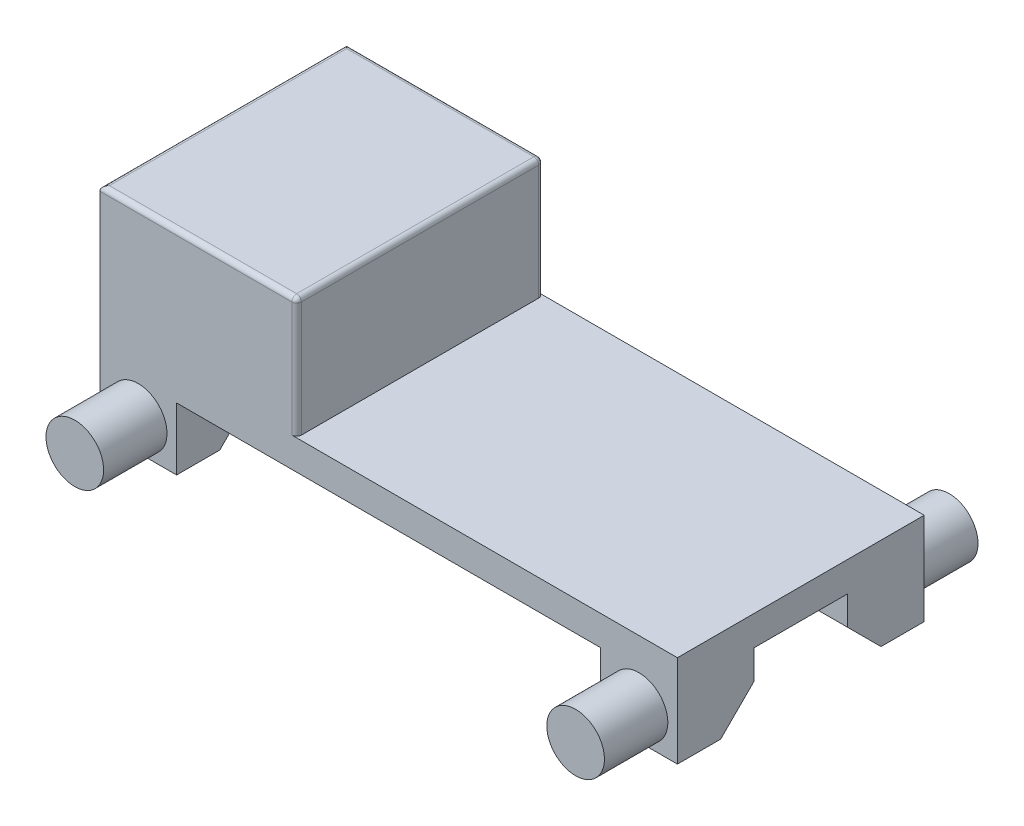
from build123d import *

# Parameters (mm, degrees)
SKETCH_1_W      = 1203
SKETCH_1_H      = 514
EXTRUDE_1_DEPTH = 62
SKETCH_2_W      = 410
SKETCH_2_H      = 514
EXTRUDE_2_DEPTH = 250
FILLET_1_R      = 10
SKETCH_3_W      = 160
SKETCH_3_H      = 160
EXTRUDE_3_DEPTH = 130
CHAMFER_1_SIZE  = 70
SKETCH_5_R      = 60
EXTRUDE_4_DEPTH = 132
SKETCH_4_R      = 60
EXTRUDE_5_DEPTH = 132


with BuildPart() as part:
    # Эскиз1 → Бобышка-Вытянуть1 (new body)
    with BuildSketch(Plane(origin=(0, 0, 0), x_dir=(1, 0, 0), z_dir=(0, 1, 0))):
        Rectangle(SKETCH_1_W, SKETCH_1_H)
    extrude(amount=EXTRUDE_1_DEPTH)

    # Эскиз2 → Бобышка-Вытянуть2 (add)
    with BuildSketch(Plane(origin=(0, 62, 0), x_dir=(1, 0, 0), z_dir=(0, 1, 0))):
        with Locations((-396.5, 0)):
            Rectangle(SKETCH_2_W, SKETCH_2_H)
    extrude(amount=EXTRUDE_2_DEPTH)

    # Скругление1
    fillet_1_edges = [part.edges().sort_by_distance(p)[0] for p in [
        (-191.5, 187, 257),
        (-191.5, 187, -257),
        (-601.5, 312, 0),
        (-396.5, 312, 257),
        (-191.5, 312, 0),
        (-396.5, 312, -257),
    ]]
    fillet(fillet_1_edges, radius=FILLET_1_R)

    # Эскиз3 → Бобышка-Вытянуть3 (add)
    with BuildSketch(Plane.XZ):
        with Locations((-521.5, 177)):
            Rectangle(SKETCH_3_W, SKETCH_3_H)
        with Locations((-521.5, -177)):
            Rectangle(SKETCH_3_W, SKETCH_3_H)
        with Locations((521.5, -177)):
            Rectangle(SKETCH_3_W, SKETCH_3_H)
        with Locations((521.5, 177)):
            Rectangle(SKETCH_3_W, SKETCH_3_H)
    extrude(amount=EXTRUDE_3_DEPTH)

    # Фаска1
    chamfer_1_edges = [part.edges().sort_by_distance(p)[0] for p in [
        (521.5, -130, 97),
        (-521.5, -130, 97),
        (-521.5, -130, -97),
        (521.5, -130, -97),
    ]]
    chamfer(chamfer_1_edges, length=CHAMFER_1_SIZE)

    # Эскиз5 → Бобышка-Вытянуть4 (add)
    with BuildSketch(Plane(origin=(0, 0, -257), x_dir=(-1, 0, 0), z_dir=(0, 0, -1))):
        with Locations((521.5, -65)):
            Circle(SKETCH_5_R)
        with Locations((-521.5, -65)):
            Circle(SKETCH_5_R)
    extrude(amount=EXTRUDE_4_DEPTH)

    # Эскиз4 → Бобышка-Вытянуть5 (add)
    with BuildSketch(Plane.XY.offset(257)):
        with Locations((-521.5, -65)):
            Circle(SKETCH_4_R)
        with Locations((521.5, -65)):
            Circle(SKETCH_4_R)
    extrude(amount=EXTRUDE_5_DEPTH)


solid = part.part
